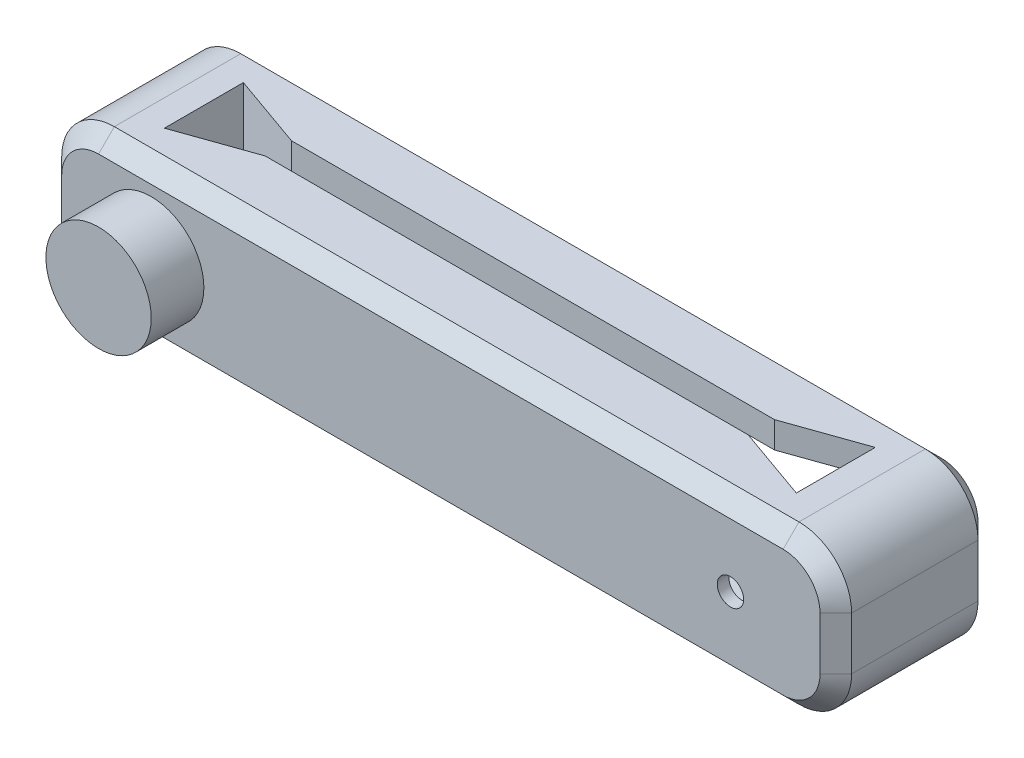
from build123d import *

# Parameters (mm, degrees)
SKETCH1_W           = 150
SKETCH1_H           = 30
BOSS_EXTRUDE1_DEPTH = 30
SKETCH2_R           = 10
BOSS_EXTRUDE2_DEPTH = 10
FILLET1_R           = 10
SKETCH3_W           = 40
SKETCH3_H           = 20
CUT_EXTRUDE1_DEPTH  = 27.8
SKETCH4_R           = 2.5
CUT_EXTRUDE2_DEPTH  = 27.8
CUT_EXTRUDE3_DEPTH  = 31
CHAMFER1_SIZE       = 3


with BuildPart() as part:
    # Sketch1 → Boss-Extrude1 (new body)
    with BuildSketch(Plane.XY):
        Rectangle(SKETCH1_W, SKETCH1_H)
    extrude(amount=BOSS_EXTRUDE1_DEPTH)

    # Sketch2 → Boss-Extrude2 (add)
    with BuildSketch(Plane.XY.offset(30)):
        with Locations((-55, 0)):
            Circle(SKETCH2_R)
    extrude(amount=BOSS_EXTRUDE2_DEPTH)

    # Fillet1
    fillet1_edges = [part.edges().sort_by_distance(p)[0] for p in [
        (75, -15, 15),
        (-75, -15, 15),
        (-75, 15, 15),
        (75, 15, 15),
    ]]
    fillet(fillet1_edges, radius=FILLET1_R)

    # Sketch3 → Cut-Extrude1 (cut)
    with BuildSketch(Plane(origin=(0, 0, 0), x_dir=(-1, 0, 0), z_dir=(0, 0, -1))):
        with Locations((-45, 0)):
            Rectangle(SKETCH3_W, SKETCH3_H)
    extrude(amount=-CUT_EXTRUDE1_DEPTH, mode=Mode.SUBTRACT)

    # Sketch4 → Cut-Extrude2 (cut)
    with BuildSketch(Plane(origin=(0, 0, 27.8), x_dir=(-1, 0, 0), z_dir=(0, 0, -1))):
        with Locations((-55, 0)):
            Circle(SKETCH4_R)
    extrude(amount=-CUT_EXTRUDE2_DEPTH, mode=Mode.SUBTRACT)

    # Sketch5 → Cut-Extrude3 (cut, through all)
    with BuildSketch(Plane(origin=(0, 15, 0), x_dir=(1, 0, 0), z_dir=(0, 1, 0))):
        Polygon((-60, -7.5), (-60, -22.5), (-45.857864376, -17.5), (45.857864376, -17.5), (60, -22.5), (60, -7.5), (45.857864376, -12.5), (-45.857864376, -12.5), align=None)
    extrude(amount=-CUT_EXTRUDE3_DEPTH, mode=Mode.SUBTRACT)

    # Chamfer1
    chamfer1_edges = [part.edges().sort_by_distance(p)[0] for p in [
        (75, 0, 0),
        (75, 0, 30),
        (0, -15, 0),
        (-75, 0, 0),
        (0, 15, 0),
        (-72.071067812, 12.071067812, 0),
        (-72.071067812, -12.071067812, 0),
        (72.071067812, 12.071067812, 0),
        (72.071067812, -12.071067812, 0),
        (0, -15, 30),
        (0, 15, 30),
        (-75, 0, 30),
        (-72.071067812, 12.071067812, 30),
        (-72.071067812, -12.071067812, 30),
        (72.071067812, 12.071067812, 30),
        (72.071067812, -12.071067812, 30),
    ]]
    chamfer(chamfer1_edges, length=CHAMFER1_SIZE)


solid = part.part
